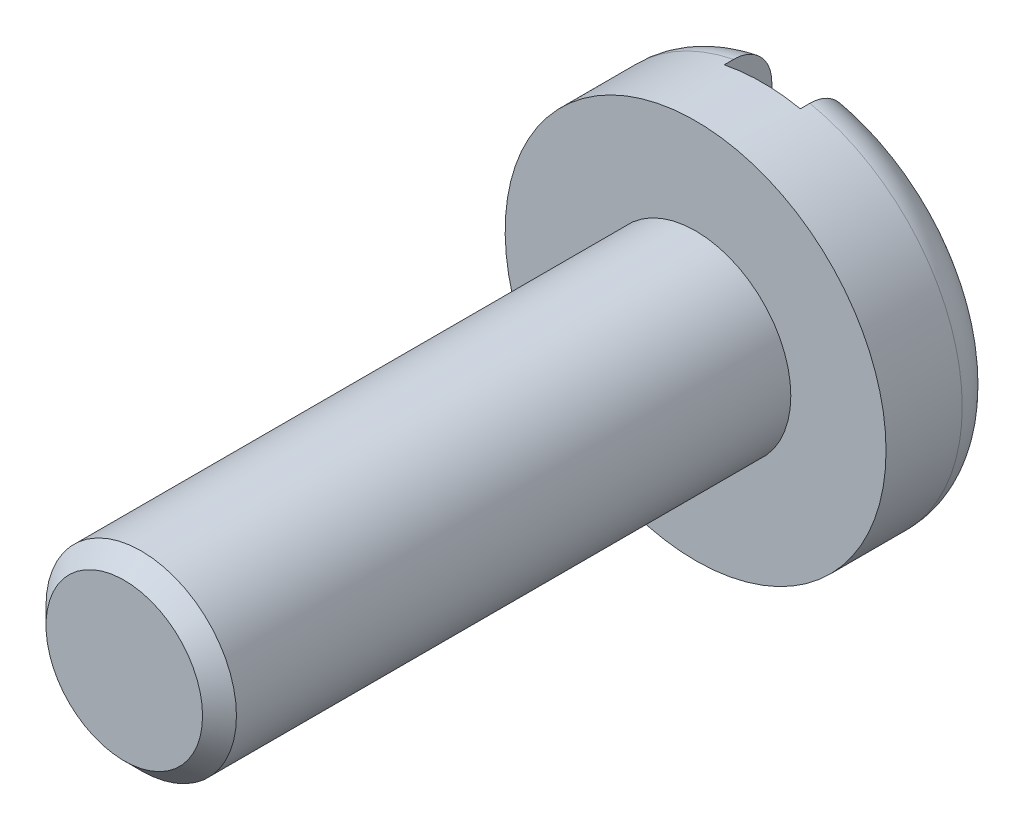
from build123d import *

# Parameters (mm, degrees)
SKETCH_1_R               = 5
EXTRUDE_1_DEPTH          = 3
SKETCH_2_R               = 2.5
EXTRUDE_2_DEPTH          = 15
FILLET_1_R               = 1
SKETCH_3_W               = 2
SKETCH_3_H               = 2.5
CUT_EXTRUDE_1_DEPTH      = 6
CUT_EXTRUDE_1_DEPTH_BACK = 6.0000001
CHAMFER_1_SIZE           = 0.445


with BuildPart() as part:
    # Эскиз1 → Бобышка-Вытянуть1 (new body)
    with BuildSketch(Plane.XY):
        Circle(SKETCH_1_R)
    extrude(amount=EXTRUDE_1_DEPTH)

    # Эскиз2 → Бобышка-Вытянуть2 (add)
    with BuildSketch(Plane.XY.offset(3)):
        Circle(SKETCH_2_R)
    extrude(amount=EXTRUDE_2_DEPTH)

    # Скругление1
    fillet_1_edges = [part.edges().sort_by_distance(p)[0] for p in [
        (-5, 0, 0),
    ]]
    fillet(fillet_1_edges, radius=FILLET_1_R)

    # Эскиз3 → Вырез-Вытянуть1 (cut, two sides)
    with BuildSketch(Plane(origin=(0, 0, 0), x_dir=(1, 0, 0), z_dir=(0, 1, 0))) as cut_extrude_1_sk:
        Rectangle(SKETCH_3_W, SKETCH_3_H)
    extrude(amount=CUT_EXTRUDE_1_DEPTH, mode=Mode.SUBTRACT)
    extrude(cut_extrude_1_sk.sketch, amount=-CUT_EXTRUDE_1_DEPTH_BACK, mode=Mode.SUBTRACT)

    # Фаска1
    chamfer_1_edges = [part.edges().sort_by_distance(p)[0] for p in [
        (-2.5, 0, 18),
    ]]
    chamfer(chamfer_1_edges, length=CHAMFER_1_SIZE)


solid = part.part
